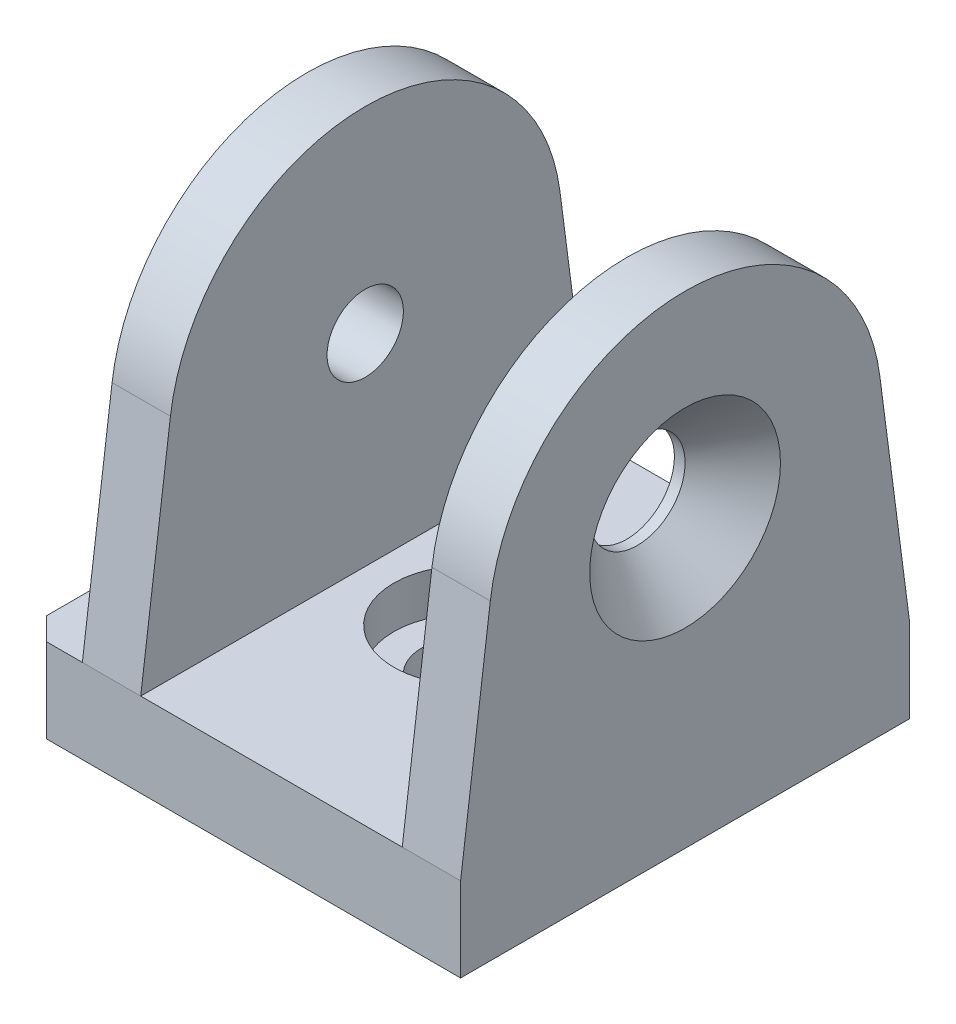
from build123d import *

# Parameters (mm, degrees)
SKETCH_1_W               = 38.9
SKETCH_1_H               = 40
EXTRUDE_1_DEPTH          = 7.5
EXTRUDE_2_DEPTH          = 33.7
SKETCH_4_W               = 23.3
SKETCH_4_H               = 35.5
CUT_EXTRUDE_1_DEPTH      = 21
CUT_EXTRUDE_1_DEPTH_BACK = 21
CHAMFER_1_SIZE           = 2
HOLE_WIZARD_M81_D        = 6.8
HOLE_WIZARD_M81_DEPTH    = 5.2


with BuildPart() as part:
    # Эскиз1 → Бобышка-Вытянуть1 (new body)
    with BuildSketch(Plane(origin=(0, 0, 0), x_dir=(1, 0, 0), z_dir=(0, 1, 0))):
        Rectangle(SKETCH_1_W, SKETCH_1_H)
    extrude(amount=EXTRUDE_1_DEPTH)

    # Эскиз2 → Вырез-Повернуть1 (revolve, cut)
    with BuildSketch(Plane.XY):
        Polygon((-4, 0), (-4, 3.75), (-6.5, 3.75), (-6.5, 7.5), (0, 7.5), (0, 0), align=None)
    revolve(axis=Axis((0, 7.5, 0), (0, -1, 0)), mode=Mode.SUBTRACT)

    # Эскиз3 → Бобышка-Вытянуть2 (add)
    with BuildSketch(Plane(origin=(19.45, 0, 0), x_dir=(0, 0, -1), z_dir=(1, 0, 0))):
        with BuildLine():
            Line((-20, 7.5), (-17.35257463, 27.766749589))
            ThreePointArc((-17.35257463, 27.766749589), (0, 43), (17.35257463, 27.766749589))
            Line((17.35257463, 27.766749589), (20, 7.5))
            Line((20, 7.5), (-20, 7.5))
        make_face()
    extrude(amount=-EXTRUDE_2_DEPTH)

    # Эскиз4 → Вырез-Вытянуть1 (cut, two sides)
    with BuildSketch(Plane.XY) as cut_extrude_1_sk:
        with Locations((2.6, 25.25)):
            Rectangle(SKETCH_4_W, SKETCH_4_H)
    extrude(amount=CUT_EXTRUDE_1_DEPTH, mode=Mode.SUBTRACT)
    extrude(cut_extrude_1_sk.sketch, amount=-CUT_EXTRUDE_1_DEPTH_BACK, mode=Mode.SUBTRACT)

    # Фаска1
    chamfer_1_edges = [part.edges().sort_by_distance(p)[0] for p in [
        (-19.45, 3.75, -20),
        (-19.45, 3.75, 20),
    ]]
    chamfer(chamfer_1_edges, length=CHAMFER_1_SIZE)

    # Эскиз10 → Зенковка для винта с полупотайной головкой 1 (revolve, cut)
    with BuildSketch(Plane(origin=(19.45, 25.5, 0), x_dir=(0, 0, -1), z_dir=(0, 1, 0))):
        Polygon((0, 0), (0, 5.2), (4.25, 5.2), (4.25, 4.25), (8.5, 0), align=None)
    revolve(axis=Axis((25.8, 25.5, 0), (-1, 0, 0)), mode=Mode.SUBTRACT)

    # Отверстие обработанное метчиком M81
    with Locations(Plane.ZY.offset(14.25)):
        with Locations((0, 25.5)):
            Hole(HOLE_WIZARD_M81_D / 2, depth=HOLE_WIZARD_M81_DEPTH)


solid = part.part
